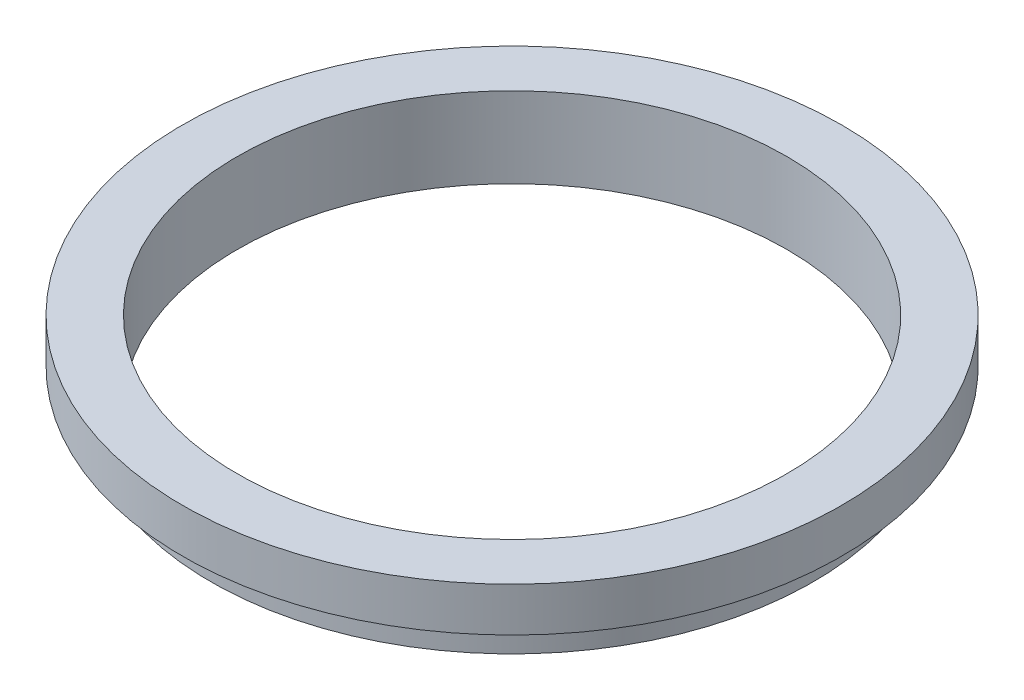
from build123d import *


with BuildPart() as part:
    # Esquisse1 → Révolution1 (revolve)
    with BuildSketch(Plane.XY):
        with BuildLine():
            Line((143.396454905, 12.7), (142.494, 12.7))
            Line((142.494, 12.7), (142.494, 0))
            Line((142.494, 0), (130.048, 0))
            Line((130.048, 0), (130.048, 38.1))
            Line((130.048, 38.1), (155.956, 38.1))
            Line((155.956, 38.1), (155.956, 17.260162249))
            Line((155.956, 17.260162249), (149.676227452, 17.260162249))
            ThreePointArc((149.676227452, 17.260162249), (145.79580792, 15.999865109), (143.396454905, 12.7))
        make_face()
    revolve(axis=Axis((0, 0, 0), (0, 1, 0)))


solid = part.part
